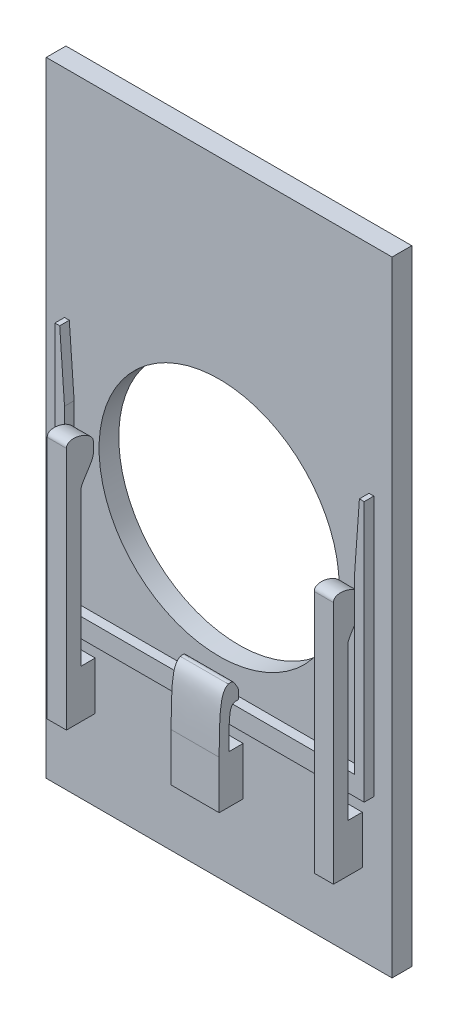
from build123d import *

# Parameters (mm, degrees)
MAIN_FEATURES_SKETCH_W = 36
MAIN_FEATURES_SKETCH_H = 65
MAIN_FEATURES_SKETCH_R = 12.5
BASE_FILTER_DEPTH      = 2.05
LENS_SURROUND_DEPTH    = 3.05
ARM_DEPTH              = 2.5
FILLET1_R              = 0.5
LONG_ARM_START         = 0.2
LONG_ARM_DEPTH         = 2


with BuildPart() as part:
    # main_features_sketch → base_filter (new body)
    with BuildSketch(Plane.XY):
        Rectangle(MAIN_FEATURES_SKETCH_W, MAIN_FEATURES_SKETCH_H)
        Circle(MAIN_FEATURES_SKETCH_R, mode=Mode.SUBTRACT)
    extrude(amount=BASE_FILTER_DEPTH)

    # main_features_sketch_4 → lens_surround (add)
    with BuildSketch(Plane.XY):
        Polygon((-16.1, 10), (-16.1, 0), (-16.1, -17.1), (16.1, -17.1), (16.1, 0), (16.1, 10), (15.6, 10), (15.1, 3), (15.1, 0), (15.1, -15.1), (-15.1, -15.1), (-15.1, 0), (-15.1, 3), (-15.6, 10), align=None)
    extrude(amount=LENS_SURROUND_DEPTH)

    # arm_sketch → arm (add, symmetric)
    with BuildSketch(Plane(origin=(0, 0, 0), x_dir=(0, -1, 0), z_dir=(-1, 0, 0))):
        with BuildLine():
            Line((13.9, 2.549398771), (14.9, 2.549398771))
            add(Edge.make_bspline(
                [(19.1, 3.55), (14.882914348, 3.55), (14.9, 3.386309971), (14.9, 2.549398771)],
                knots=[0, 0, 0, 0, 1, 1, 1, 1], degree=3))
            Line((19.1, 3.55), (19.1, 2.05))
            Line((19.1, 2.05), (24.1, 2.05))
            Line((24.1, 2.05), (24.1, 3.55))
            Line((24.1, 3.55), (24.1, 4.55))
            Line((24.1, 4.55), (19.1, 4.55))
            add(Edge.make_bspline(
                [(19.1, 4.55), (14.0970617, 4.55), (12.9, 4.338647065), (12.9, 3.134725983)],
                knots=[0, 0, 0, 0, 1, 1, 1, 1], degree=3))
            Line((12.9, 3.134725983), (13.9, 2.549398771))
        make_face()
    extrude(amount=ARM_DEPTH, both=True)

    # Fillet1
    fillet1_edges = [part.edges().sort_by_distance(p)[0] for p in [
        (0, -13.9, 2.549398771),
        (1.25, -12.9, 3.134725983),
    ]]
    fillet(fillet1_edges, radius=FILLET1_R)

    # long_arm_sketch → long_arm (add)
    with BuildSketch(Plane(origin=(-15.1, 0, 0), x_dir=(0, 0, -1), z_dir=(1, 0, 0)).offset(LONG_ARM_START)):
        with BuildLine():
            Line((-2.05, -24.1), (-5.05, -24.1))
            Line((-5.05, -24.1), (-5.05, 1.297726723))
            add(Edge.make_bspline(
                [(-5.05, 1.297726723), (-5.05, 2.39434011), (-2.25, 1.5663534), (-2.25, 0.537583105)],
                knots=[0, 0, 0, 0, 1, 1, 1, 1], degree=3))
            Line((-2.25, 0.537583105), (-2.25, -0.537583105))
            add(Edge.make_bspline(
                [(-3.55, -3.211240123), (-3.55, -2.566791116), (-2.25, -1.290352393), (-2.25, -0.537583105)],
                knots=[0, 0, 0, 0, 1, 1, 1, 1], degree=3))
            Line((-3.55, -3.211240123), (-3.55, -19.1))
            Line((-3.55, -19.1), (-2.05, -19.1))
            Line((-2.05, -19.1), (-2.05, -24.1))
        make_face()
    long_arm = extrude(amount=LONG_ARM_DEPTH)

    # Mirror1: long_arm across plane
    add(long_arm.mirror(Plane(origin=(0, 0, 0), x_dir=(0, 0, 1), z_dir=(1, 0, 0))))


solid = part.part
